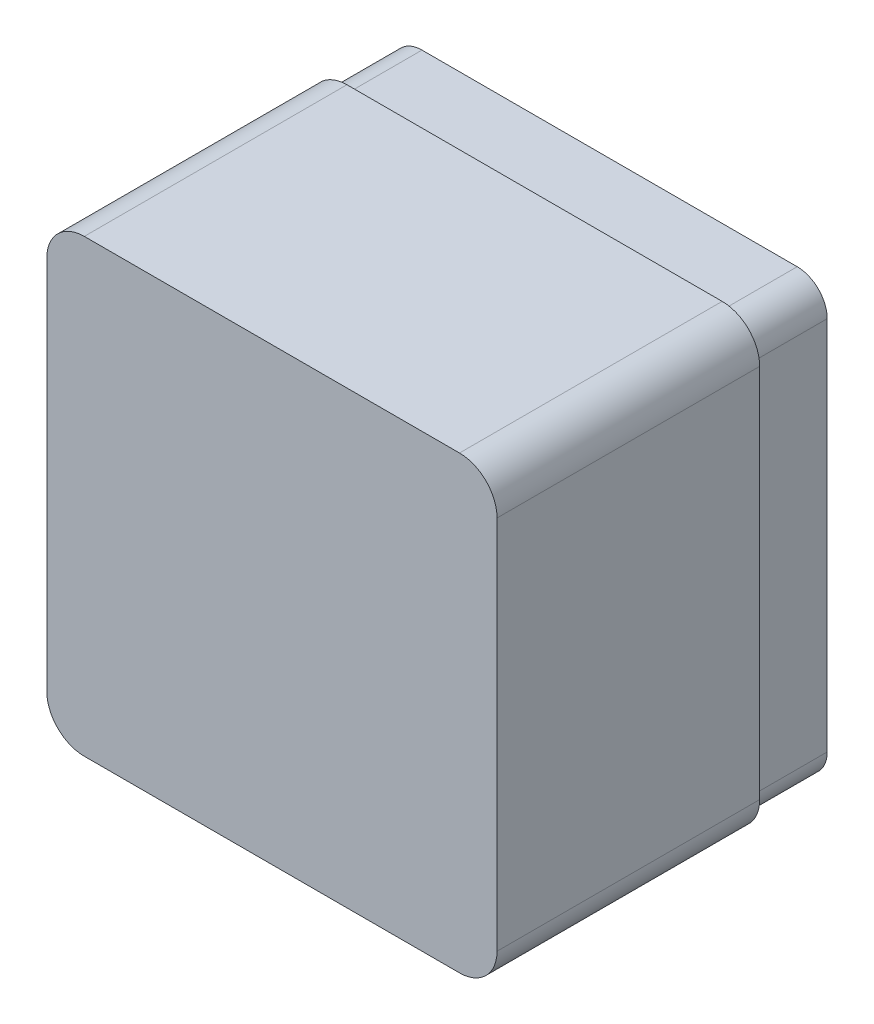
from build123d import *

# Parameters (mm, degrees)
SKETCH1_W           = 120
SKETCH1_H           = 120
BOSS_EXTRUDE1_DEPTH = 90
FILLET2_R           = 10
SHELL1_T            = -4
CUT_EXTRUDE1_DEPTH  = 20


with BuildPart() as part:
    # Sketch1 → Boss-Extrude1 (new body)
    with BuildSketch(Plane.XY):
        with Locations((60, 60)):
            Rectangle(SKETCH1_W, SKETCH1_H)
    extrude(amount=BOSS_EXTRUDE1_DEPTH)

    # Fillet2
    fillet2_edges = [part.edges().sort_by_distance(p)[0] for p in [
        (0, 0, 45),
        (120, 0, 45),
        (120, 120, 45),
        (0, 120, 45),
    ]]
    fillet(fillet2_edges, radius=FILLET2_R)

    # Shell1
    shell1_openings = [part.faces().sort_by_distance(p)[0] for p in [
        (60, 60, 0),
    ]]
    offset(amount=SHELL1_T, openings=shell1_openings, kind=Kind.INTERSECTION)

    # Sketch2 → Cut-Extrude1 (cut)
    with BuildSketch(Plane(origin=(0, 0, 0), x_dir=(-1, 0, 0), z_dir=(0, 0, -1))):
        with BuildLine():
            Line((-10, 120), (-110, 120))
            ThreePointArc((-110, 120), (-117.071067812, 117.071067812), (-120, 110))
            Line((-120, 110), (-120, 10))
            ThreePointArc((-120, 10), (-117.071067812, 2.928932188), (-110, 0))
            Line((-110, 0), (-10, 0))
            ThreePointArc((-10, 0), (-2.928932188, 2.928932188), (0, 10))
            Line((0, 10), (0, 110))
            ThreePointArc((0, 110), (-2.928932188, 117.071067812), (-10, 120))
        make_face()
        with BuildLine():
            Line((-10, 118), (-110, 118))
            ThreePointArc((-110, 118), (-115.656854249, 115.656854249), (-118, 110))
            Line((-118, 110), (-118, 10))
            ThreePointArc((-118, 10), (-115.656854249, 4.343145751), (-110, 2))
            Line((-110, 2), (-10, 2))
            ThreePointArc((-10, 2), (-4.343145751, 4.343145751), (-2, 10))
            Line((-2, 10), (-2, 110))
            ThreePointArc((-2, 110), (-4.343145751, 115.656854249), (-10, 118))
        make_face(mode=Mode.SUBTRACT)
    extrude(amount=-CUT_EXTRUDE1_DEPTH, mode=Mode.SUBTRACT)


solid = part.part
